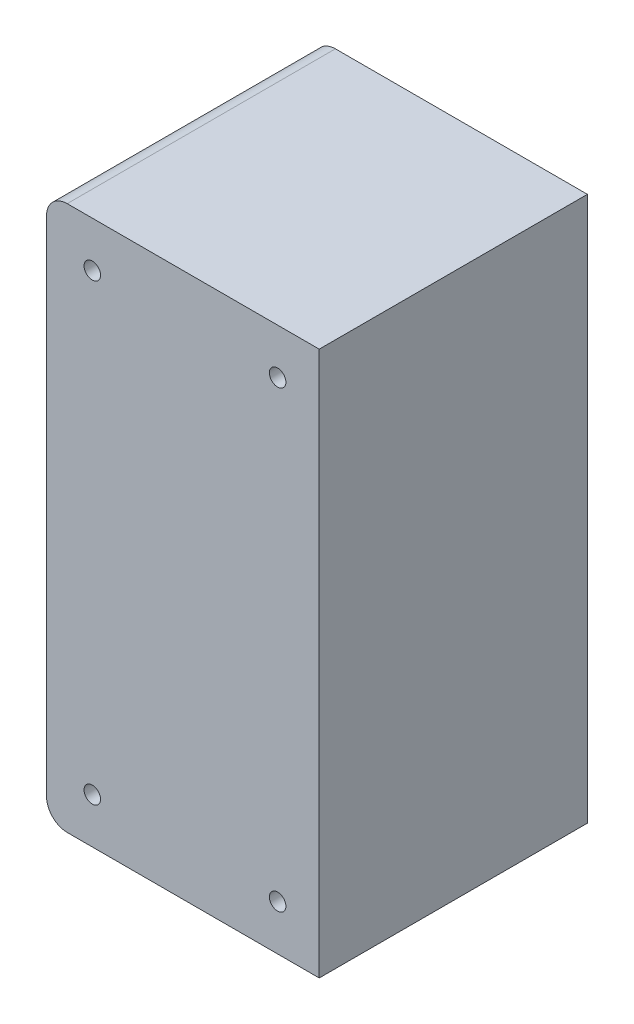
from build123d import *

# Parameters (mm, degrees)
SKETCH1_R           = 2
BOSS_EXTRUDE1_DEPTH = 65
SHELL1_T            = -4
SKETCH2_R           = 6
CUT_EXTRUDE1_DEPTH  = 61


with BuildPart() as part:
    # Sketch1 → Boss-Extrude1 (new body)
    with BuildSketch(Plane.XY):
        with BuildLine():
            Line((-33.042, 61), (-33.042, -61))
            ThreePointArc((-33.042, -61), (-31.577533906, -64.535533906), (-28.042, -66))
            Line((-28.042, -66), (33.042, -66))
            Line((33.042, -66), (33.042, 66))
            Line((33.042, 66), (-28.042, 66))
            ThreePointArc((-28.042, 66), (-31.577533906, 64.535533906), (-33.042, 61))
        make_face()
        with Locations((22.958, -55)):
            Circle(SKETCH1_R, mode=Mode.SUBTRACT)
        with Locations((-21.958, 55)):
            Circle(SKETCH1_R, mode=Mode.SUBTRACT)
        with Locations((-21.958, -55)):
            Circle(SKETCH1_R, mode=Mode.SUBTRACT)
        with Locations((22.958, 55)):
            Circle(SKETCH1_R, mode=Mode.SUBTRACT)
    extrude(amount=BOSS_EXTRUDE1_DEPTH)

    # Shell1
    shell1_openings = [part.faces().sort_by_distance(p)[0] for p in [
        (-9.692511302, 0, 0),
    ]]
    offset(amount=SHELL1_T, openings=shell1_openings, kind=Kind.INTERSECTION)

    # Sketch2 → Cut-Extrude1 (cut)
    with BuildSketch(Plane(origin=(0, 0, 0), x_dir=(-1, 0, 0), z_dir=(0, 0, -1))):
        with Locations((-22.958, -55)):
            Circle(SKETCH2_R)
        with Locations((21.958, -55)):
            Circle(SKETCH2_R)
        with Locations((21.958, 55)):
            Circle(SKETCH2_R)
        with Locations((-22.958, 55)):
            Circle(SKETCH2_R)
    extrude(amount=-CUT_EXTRUDE1_DEPTH, mode=Mode.SUBTRACT)


solid = part.part
